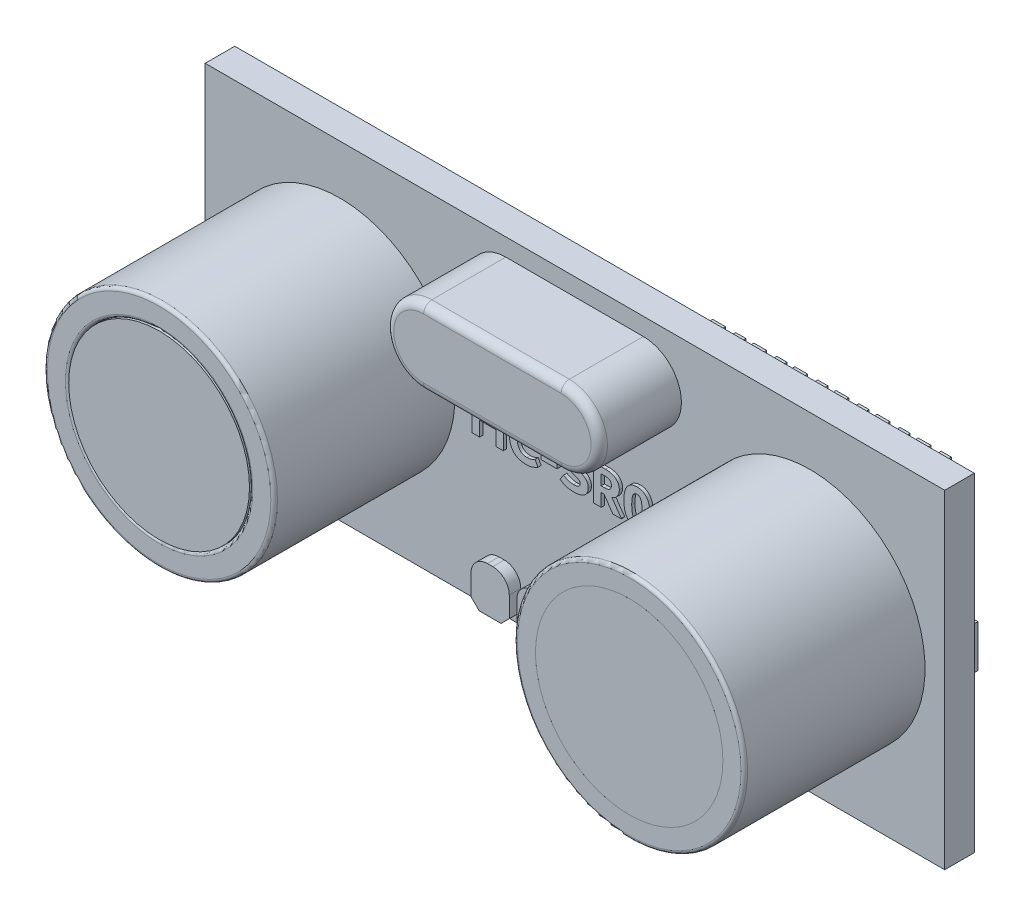
from build123d import *

# Parameters (mm, degrees)
SKETCH2_W            = 45
SKETCH2_H            = 20
BOSS_EXTRUDE1_DEPTH  = 1.8
SKETCH3_R            = 7
SKETCH3_R_2          = 5.5
BOSS_EXTRUDE2_DEPTH  = 11
SKETCH4_R            = 3.606638941
BOSS_EXTRUDE3_DEPTH  = 3
BOSS_EXTRUDE4_DEPTH  = 5
FILLET1_R            = 0.5
FILLET2_R            = 0.2
SKETCH6_R            = 5.5
BOSS_EXTRUDE5_DEPTH  = 0.2
SKETCH8_R            = 5.7
BOSS_EXTRUDE7_DEPTH  = 0.3
BOSS_EXTRUDE8_DEPTH  = 0.7
SKETCH12_W           = 6.997666704
SKETCH12_H           = 2.580972028
SKETCH12_W_2         = 7.281355894
SKETCH12_W_3         = 3.593396415
SKETCH12_H_2         = 7.186792831
BOSS_EXTRUDE9_DEPTH  = 1
SKETCH13_W           = 0.620394056
SKETCH13_H           = 1.706083654
SKETCH13_W_2         = 0.77549257
BOSS_EXTRUDE10_DEPTH = 0.8
SKETCH15_W           = 0.778606998
SKETCH15_H           = 1.881633579
SKETCH15_W_2         = 1.881633579
SKETCH15_H_2         = 0.778606999
SKETCH15_H_3         = 0.778606998
SKETCH15_W_3         = 1.881633578
SKETCH15_W_4         = 0.778606999
SKETCH15_H_4         = 1.881633578
BOSS_EXTRUDE11_DEPTH = 0.8
SKETCH16_W           = 0.977940317
SKETCH16_H           = 0.386305526
BOSS_EXTRUDE12_DEPTH = 0.2


with BuildPart() as part:
    # Sketch2 → Boss-Extrude1 (new body)
    with BuildSketch(Plane.XY):
        Rectangle(SKETCH2_W, SKETCH2_H)
    extrude(amount=BOSS_EXTRUDE1_DEPTH)

    # Sketch3 → Boss-Extrude2 (add)
    with BuildSketch(Plane.XY.offset(1.8)):
        with Locations((-14.302663364, 0)):
            Circle(SKETCH3_R)
        with Locations((-14.302663364, 0)):
            Circle(SKETCH3_R_2, mode=Mode.SUBTRACT)
        with Locations((14.302663364, 0)):
            Circle(SKETCH3_R)
        with Locations((14.302663364, 0)):
            Circle(SKETCH3_R_2, mode=Mode.SUBTRACT)
    extrude(amount=BOSS_EXTRUDE2_DEPTH)

    # Sketch4 → Boss-Extrude3 (add)
    with BuildSketch(Plane.XY.offset(1.8)):
        with Locations((-14.381398614, -0.162523466)):
            Circle(SKETCH4_R)
        with Locations((14.381398614, -0.162523466)):
            Circle(SKETCH4_R)
    extrude(amount=BOSS_EXTRUDE3_DEPTH)

    # Sketch5 → Boss-Extrude4 (add)
    with BuildSketch(Plane.XY.offset(1.8)):
        with BuildLine():
            Line((-4.2079433, 8.933531552), (4.160887825, 8.933531552))
            ThreePointArc((4.160887825, 8.933531552), (6.477682883, 6.616736495), (4.160887825, 4.299941437))
            Line((4.160887825, 4.299941437), (-4.2079433, 4.299941437))
            ThreePointArc((-4.2079433, 4.299941437), (-6.524738357, 6.616736495), (-4.2079433, 8.933531552))
        make_face()
    extrude(amount=BOSS_EXTRUDE4_DEPTH)

    # Fillet1
    fillet1_edges = [part.edges().sort_by_distance(p)[0] for p in [
        (-6.524738357, 6.616736495, 6.8),
        (-0.023527737, 4.299941437, 6.8),
        (6.477682883, 6.616736495, 6.8),
        (-0.023527737, 8.933531552, 6.8),
    ]]
    fillet(fillet1_edges, radius=FILLET1_R)

    # Fillet2
    fillet2_edges = [part.edges().sort_by_distance(p)[0] for p in [
        (-21.302663364, 0, 12.8),
        (-19.802663364, 0, 12.8),
        (7.302663364, 0, 12.8),
        (8.802663364, 0, 12.8),
    ]]
    fillet(fillet2_edges, radius=FILLET2_R)

    # Sketch9 → Boss-Extrude8 (add)
    with BuildSketch(Plane.XY.offset(1.8)):
        with BuildLine():
            Line((-3.296407127, -8.07298027), (-3.296407127, -9.317695877))
            Line((-3.296407127, -9.317695877), (-3.796407127, -9.817695877))
            Line((-3.796407127, -9.817695877), (-5.123806694, -9.817695877))
            Line((-5.123806694, -9.817695877), (-5.623806694, -9.317695877))
            Line((-5.623806694, -9.317695877), (-5.623806694, -8.07298027))
            ThreePointArc((-5.623806694, -8.07298027), (-5.330913475, -7.365873489), (-4.623806694, -7.07298027))
            Line((-4.623806694, -7.07298027), (-4.296407127, -7.07298027))
            ThreePointArc((-4.296407127, -7.07298027), (-3.589300346, -7.365873489), (-3.296407127, -8.07298027))
        make_face()
        with BuildLine():
            ThreePointArc((-2.835845474, -8.07298027), (-2.542952255, -7.365873489), (-1.835845474, -7.07298027))
            Line((-1.835845474, -7.07298027), (-1.268491023, -7.07298027))
            ThreePointArc((-1.268491023, -7.07298027), (-0.561384242, -7.365873489), (-0.268491023, -8.07298027))
            Line((-0.268491023, -8.07298027), (-0.268491023, -9.317695877))
            Line((-0.268491023, -9.317695877), (-0.768491023, -9.817695877))
            Line((-0.768491023, -9.817695877), (-2.335845474, -9.817695877))
            Line((-2.335845474, -9.817695877), (-2.835845474, -9.317695877))
            Line((-2.835845474, -9.317695877), (-2.835845474, -8.07298027))
        make_face()
        with BuildLine():
            ThreePointArc((2.975704802, -8.07298027), (3.268598021, -7.365873489), (3.975704802, -7.07298027))
            Line((3.975704802, -7.07298027), (4.516991532, -7.07298027))
            ThreePointArc((4.516991532, -7.07298027), (5.224098313, -7.365873489), (5.516991532, -8.07298027))
            Line((5.516991532, -8.07298027), (5.516991532, -9.317695877))
            Line((5.516991532, -9.317695877), (5.016991532, -9.817695877))
            Line((5.016991532, -9.817695877), (3.475704802, -9.817695877))
            Line((3.475704802, -9.817695877), (2.975704802, -9.317695877))
            Line((2.975704802, -9.317695877), (2.975704802, -8.07298027))
        make_face()
        with BuildLine():
            ThreePointArc((0.299243246, -8.07298027), (0.592136465, -7.365873489), (1.299243246, -7.07298027))
            Line((1.299243246, -7.07298027), (1.516110394, -7.07298027))
            ThreePointArc((1.516110394, -7.07298027), (2.223217175, -7.365873489), (2.516110394, -8.07298027))
            Line((2.516110394, -8.07298027), (2.516110394, -9.317695877))
            Line((2.516110394, -9.317695877), (2.016110394, -9.817695877))
            Line((2.016110394, -9.817695877), (0.799243246, -9.817695877))
            Line((0.799243246, -9.817695877), (0.299243246, -9.317695877))
            Line((0.299243246, -9.317695877), (0.299243246, -8.07298027))
        make_face()
    extrude(amount=BOSS_EXTRUDE8_DEPTH)

    # Sketch12 → Boss-Extrude9 (add)
    with BuildSketch(Plane(origin=(0, 0, 0), x_dir=(-1, 0, 0), z_dir=(0, 0, -1))):
        with Locations((-18.227030502, 0)):
            Rectangle(SKETCH12_W, SKETCH12_H)
        with Locations((-4.515386285, 0)):
            Rectangle(SKETCH12_W_2, SKETCH12_H)
        with Locations((14.586352554, 0.458930663)):
            Rectangle(SKETCH12_W_3, SKETCH12_H_2)
    extrude(amount=BOSS_EXTRUDE9_DEPTH)

    # Sketch13 → Boss-Extrude10 (add)
    with BuildSketch(Plane(origin=(0, 0, 0), x_dir=(-1, 0, 0), z_dir=(0, 0, -1))):
        with Locations((-17.492981822, 8.497814385)):
            Rectangle(SKETCH13_W, SKETCH13_H)
        with Locations((-19.992981822, 8.497814385)):
            Rectangle(SKETCH13_W, SKETCH13_H)
        with Locations((-18.674644453, 8.497814385)):
            Rectangle(SKETCH13_W_2, SKETCH13_H)
        with Locations((-16.174644453, 8.497814385)):
            Rectangle(SKETCH13_W_2, SKETCH13_H)
        with Locations((-14.992981822, 8.497814385)):
            Rectangle(SKETCH13_W, SKETCH13_H)
        with Locations((-13.674644453, 8.497814385)):
            Rectangle(SKETCH13_W_2, SKETCH13_H)
        with Locations((-12.492981822, 8.497814385)):
            Rectangle(SKETCH13_W, SKETCH13_H)
        with Locations((-11.174644453, 8.497814385)):
            Rectangle(SKETCH13_W_2, SKETCH13_H)
        with Locations((-9.992981822, 8.497814385)):
            Rectangle(SKETCH13_W, SKETCH13_H)
        with Locations((-8.674644453, 8.497814385)):
            Rectangle(SKETCH13_W_2, SKETCH13_H)
        with Locations((-7.492981822, 8.497814385)):
            Rectangle(SKETCH13_W, SKETCH13_H)
        with Locations((-6.174644453, 8.497814385)):
            Rectangle(SKETCH13_W_2, SKETCH13_H)
        with Locations((-17.492981822, -5.502185615)):
            Rectangle(SKETCH13_W, SKETCH13_H)
        with Locations((-16.174644453, -5.502185615)):
            Rectangle(SKETCH13_W_2, SKETCH13_H)
        with Locations((-14.992981822, -5.502185615)):
            Rectangle(SKETCH13_W, SKETCH13_H)
        with Locations((-13.674644453, -5.502185615)):
            Rectangle(SKETCH13_W_2, SKETCH13_H)
        with Locations((-12.492981822, -5.502185615)):
            Rectangle(SKETCH13_W, SKETCH13_H)
        with Locations((-11.174644453, -5.502185615)):
            Rectangle(SKETCH13_W_2, SKETCH13_H)
        with Locations((-9.992981822, -5.502185615)):
            Rectangle(SKETCH13_W, SKETCH13_H)
        with Locations((-8.674644453, -5.502185615)):
            Rectangle(SKETCH13_W_2, SKETCH13_H)
        with Locations((-7.492981822, -5.502185615)):
            Rectangle(SKETCH13_W, SKETCH13_H)
        with Locations((-6.174644453, -5.502185615)):
            Rectangle(SKETCH13_W_2, SKETCH13_H)
        with Locations((-19.992981822, -5.502185615)):
            Rectangle(SKETCH13_W, SKETCH13_H)
        with Locations((-18.674644453, -5.502185615)):
            Rectangle(SKETCH13_W_2, SKETCH13_H)
    extrude(amount=BOSS_EXTRUDE10_DEPTH)

    # Sketch15 → Boss-Extrude11 (add)
    with BuildSketch(Plane(origin=(0, 0, 0), x_dir=(-1, 0, 0), z_dir=(0, 0, -1))):
        with Locations((4.436153711, 3.859373901)):
            Rectangle(SKETCH15_W, SKETCH15_H)
        with Locations((4.436153711, -0.149576125)):
            Rectangle(SKETCH15_W, SKETCH15_H)
        with Locations((2.818394099, 1.651139133)):
            Rectangle(SKETCH15_W, SKETCH15_H)
        with Locations((15.278254299, -7.403939958)):
            Rectangle(SKETCH15_W_2, SKETCH15_H_2)
        with Locations((13.07001953, -5.786180346)):
            Rectangle(SKETCH15_W_2, SKETCH15_H_3)
        with Locations((17.078969556, -5.786180346)):
            Rectangle(SKETCH15_W_2, SKETCH15_H_3)
        with Locations((-11.40707472, 2.879595245)):
            Rectangle(SKETCH15_W_2, SKETCH15_H_3)
        with Locations((1.45501374, 8.522939867)):
            Rectangle(SKETCH15_W_3, SKETCH15_H_3)
        with Locations((13.861551289, 8.522939867)):
            Rectangle(SKETCH15_W_2, SKETCH15_H_3)
        with Locations((17.870501316, 8.522939867)):
            Rectangle(SKETCH15_W_2, SKETCH15_H_3)
        with Locations((7.763207417, 3.859373901)):
            Rectangle(SKETCH15_W, SKETCH15_H)
        with Locations((6.145447805, 1.651139133)):
            Rectangle(SKETCH15_W_4, SKETCH15_H)
        with Locations((7.763207417, -0.149576125)):
            Rectangle(SKETCH15_W, SKETCH15_H)
        with Locations((-15.265133185, 3.268898744)):
            Rectangle(SKETCH15_W, SKETCH15_H_4)
        with Locations((10.154397832, -2.650143964)):
            Rectangle(SKETCH15_W_2, SKETCH15_H_3)
        with Locations((6.145447805, -2.650143964)):
            Rectangle(SKETCH15_W_2, SKETCH15_H_3)
    extrude(amount=BOSS_EXTRUDE11_DEPTH)

    # Sketch16 → Boss-Extrude12 (add)
    with BuildSketch(Plane.XY.offset(1.8)):
        Polygon((-4.614623459, 0.989969493), (-4.159078995, 0.989969493), (-4.159078995, -1.149274951), (-4.614623459, -1.149274951), (-4.614623459, -0.261584009), (-5.598293896, -0.261584009), (-5.598293896, -1.149274951), (-6.05383836, -1.149274951), (-6.05383836, 0.989969493), (-5.598293896, 0.989969493), (-5.598293896, 0.134271715), (-4.614623459, 0.134271715), align=None)
        with BuildLine():
            add(Edge.make_bspline(
                [(-2.758542398, -1.179835586), (-2.80187664, -1.178955464), (-2.885596469, -1.177255107), (-3.006695539, -1.163195093), (-3.118814713, -1.140601797), (-3.222290792, -1.108873564), (-3.31660546, -1.067012359), (-3.402238463, -1.016483129), (-3.47869818, -0.95607153), (-3.545546014, -0.886382582), (-3.603845021, -0.809125233), (-3.65404661, -0.725337162), (-3.697369581, -0.635842986), (-3.732010739, -0.539725429), (-3.759438653, -0.437689309), (-3.777979965, -0.329125864), (-3.790453858, -0.214601041), (-3.791709684, -0.136033786), (-3.792351376, -0.095888067)],
                knots=[0, 0, 0, 0, 0.00012997, 0.000251097, 0.000365161, 0.000472695, 0.000575093, 0.000674019, 0.000770222, 0.000866467, 0.000962925, 0.001059968, 0.001159066, 0.001260731, 0.001366019, 0.001475614, 0.001590836, 0.001711229, 0.001711229, 0.001711229, 0.001711229], degree=3))
            add(Edge.make_bspline(
                [(-3.792351376, -0.095888067), (-3.791822721, -0.063250776), (-3.790792806, 0.0003326), (-3.784820228, 0.093462721), (-3.773598156, 0.18169843), (-3.759229146, 0.265545694), (-3.739584757, 0.34449491), (-3.715606153, 0.418592185), (-3.688250618, 0.48835354), (-3.655333083, 0.552772361), (-3.619624533, 0.613197884), (-3.580488153, 0.668934089), (-3.538608713, 0.720401393), (-3.494420927, 0.767845351), (-3.446801433, 0.810444616), (-3.396694243, 0.848905976), (-3.343221649, 0.882324744), (-3.287326919, 0.911911458), (-3.229067928, 0.937735057), (-3.168712051, 0.959355259), (-3.107076402, 0.978883648), (-3.04334277, 0.993950716), (-2.977835979, 1.005895105), (-2.91058762, 1.014577249), (-2.841535022, 1.019203589), (-2.794998458, 1.020084227), (-2.771435166, 1.020530128)],
                knots=[0, 0, 0, 0, 9.7919e-05, 0.000190763, 0.000279783, 0.000364648, 0.000445833, 0.000523603, 0.000598175, 0.000670355, 0.000740374, 0.000808597, 0.000874449, 0.000939309, 0.001002877, 0.00106591, 0.001128573, 0.001191802, 0.001255509, 0.00131956, 0.001384052, 0.001449373, 0.001515872, 0.001583748, 0.001652675, 0.001723372, 0.001723372, 0.001723372, 0.001723372], degree=3))
            add(Edge.make_bspline(
                [(-2.771435166, 1.020530128), (-2.738625698, 1.020028472), (-2.674149486, 1.019042632), (-2.579661415, 1.009866748), (-2.489383691, 0.994511909), (-2.402532635, 0.973406459), (-2.317760913, 0.945748739), (-2.23361758, 0.912135134), (-2.149183122, 0.872674609), (-2.09444195, 0.841529469), (-2.066630523, 0.82570608)],
                knots=[0, 0, 0, 0, 9.8409e-05, 0.00019339, 0.000284453, 0.000372936, 0.000461275, 0.00055172, 0.000644638, 0.000740599, 0.000740599, 0.000740599, 0.000740599], degree=3))
            Line((-2.066630523, 0.82570608), (-2.241876664, 0.479033878))
            add(Edge.make_bspline(
                [(-2.241876664, 0.479033878), (-2.26141849, 0.491314035), (-2.300137703, 0.515645334), (-2.36132151, 0.545922953), (-2.423259473, 0.572319222), (-2.486385802, 0.594017993), (-2.550989694, 0.610166675), (-2.616687134, 0.622118995), (-2.683722883, 0.629517226), (-2.728759178, 0.63042572), (-2.751379749, 0.630882033)],
                knots=[0, 0, 0, 0, 6.9199e-05, 0.000137108, 0.000204512, 0.000271105, 0.000337119, 0.000404088, 0.000471322, 0.00053917, 0.00053917, 0.00053917, 0.00053917], degree=3))
            add(Edge.make_bspline(
                [(-2.751379749, 0.630882033), (-2.774006962, 0.63032934), (-2.817822736, 0.629259096), (-2.881499941, 0.621073632), (-2.940734732, 0.607393487), (-2.995771228, 0.588068365), (-3.04670018, 0.563927439), (-3.093031572, 0.533621004), (-3.134332958, 0.497197271), (-3.171775313, 0.455969504), (-3.205090156, 0.409321461), (-3.233054979, 0.356581975), (-3.257549899, 0.298845149), (-3.276870108, 0.235391485), (-3.292116456, 0.166744094), (-3.303035667, 0.092708503), (-3.309020461, 0.013083107), (-3.310024831, -0.041760578), (-3.310543866, -0.070102531)],
                knots=[0, 0, 0, 0, 6.7867e-05, 0.000131419, 0.000192228, 0.000249918, 0.000306087, 0.000360918, 0.000415406, 0.000470847, 0.000527689, 0.000586873, 0.000649574, 0.000715576, 0.000785549, 0.000860373, 0.000939883, 0.001024913, 0.001024913, 0.001024913, 0.001024913], degree=3))
            add(Edge.make_bspline(
                [(-3.310543866, -0.070102531), (-3.310096669, -0.098288574), (-3.309228525, -0.153006104), (-3.302219357, -0.232527703), (-3.289602227, -0.306644129), (-3.273355303, -0.375856327), (-3.251115094, -0.439698537), (-3.224671067, -0.498606417), (-3.192900663, -0.552076354), (-3.15645818, -0.600218777), (-3.115311022, -0.642748852), (-3.070140708, -0.679775274), (-3.020920542, -0.711375841), (-2.967205546, -0.736207207), (-2.909997614, -0.756880084), (-2.848471704, -0.770125918), (-2.783164161, -0.779177353), (-2.738202136, -0.780141608), (-2.715088995, -0.780637293)],
                knots=[0, 0, 0, 0, 8.4553e-05, 0.000164143, 0.000239191, 0.000309954, 0.000377154, 0.000441689, 0.000503354, 0.00056333, 0.000622428, 0.000680451, 0.000738206, 0.000797373, 0.000857632, 0.000920302, 0.00098581, 0.001055108, 0.001055108, 0.001055108, 0.001055108], degree=3))
            add(Edge.make_bspline(
                [(-2.715088995, -0.780637293), (-2.691508775, -0.780228522), (-2.6458247, -0.779436572), (-2.579780962, -0.771947939), (-2.518087602, -0.761011915), (-2.460318864, -0.743606798), (-2.40428795, -0.722041592), (-2.347646342, -0.697154753), (-2.29012624, -0.667980662), (-2.251826094, -0.646440798), (-2.232326465, -0.635474277)],
                knots=[0, 0, 0, 0, 7.0712e-05, 0.000136996, 0.000199183, 0.000258413, 0.000317655, 0.00037923, 0.000443936, 0.000511047, 0.000511047, 0.000511047, 0.000511047], degree=3))
            Line((-2.232326465, -0.635474277), (-2.050395186, -0.965433632))
            add(Edge.make_bspline(
                [(-2.050395186, -0.965433632), (-2.079650931, -0.982339665), (-2.137018978, -1.01549097), (-2.224741401, -1.05832536), (-2.311240452, -1.095284975), (-2.397189523, -1.126246919), (-2.484039229, -1.150756995), (-2.573279231, -1.166961728), (-2.664986321, -1.178134706), (-2.72715172, -1.179264893), (-2.758542398, -1.179835586)],
                knots=[0, 0, 0, 0, 0.000101341, 0.000198722, 0.000292647, 0.00038342, 0.000472626, 0.000563002, 0.000655284, 0.000749413, 0.000749413, 0.000749413, 0.000749413], degree=3))
        make_face()
        with Locations((-1.378061217, -0.272805492)):
            Rectangle(SKETCH16_W, SKETCH16_H)
        with BuildLine():
            add(Edge.make_bspline(
                [(0.14328539, -1.179835586), (0.102342007, -1.179228217), (0.022008476, -1.178036519), (-0.096025855, -1.164915061), (-0.209437589, -1.145291044), (-0.318342238, -1.116968135), (-0.422472784, -1.080730944), (-0.522091339, -1.036566673), (-0.616933853, -0.984207532), (-0.676137535, -0.943035381), (-0.705727249, -0.922457739)],
                knots=[0, 0, 0, 0, 0.000122779, 0.000240901, 0.000355834, 0.000467831, 0.000578072, 0.00068624, 0.000794397, 0.000902467, 0.000902467, 0.000902467, 0.000902467], degree=3))
            Line((-0.705727249, -0.922457739), (-0.491802805, -0.595363444))
            add(Edge.make_bspline(
                [(-0.491802805, -0.595363444), (-0.466244068, -0.611052361), (-0.416041042, -0.641868873), (-0.338211964, -0.680301833), (-0.261934865, -0.715144543), (-0.185330792, -0.741822263), (-0.109651457, -0.764137782), (-0.033925633, -0.778262583), (0.041122362, -0.788808698), (0.091200008, -0.789729997), (0.116067324, -0.790187491)],
                knots=[0, 0, 0, 0, 8.9919e-05, 0.000176621, 0.000260207, 0.000341312, 0.000419759, 0.000496644, 0.000572219, 0.000646766, 0.000646766, 0.000646766, 0.000646766], degree=3))
            add(Edge.make_bspline(
                [(0.116067324, -0.790187491), (0.146179994, -0.789447666), (0.203106031, -0.788049075), (0.283596818, -0.777927184), (0.353860702, -0.760120761), (0.405195954, -0.738740266), (0.440368555, -0.717836557), (0.462687901, -0.700336873), (0.481527993, -0.680990714), (0.497337413, -0.660163467), (0.509064927, -0.637122117), (0.518006084, -0.612479667), (0.522569677, -0.585819104), (0.523422433, -0.567522919), (0.523860797, -0.55811767)],
                knots=[0, 0, 0, 0, 9.033e-05, 0.000170763, 0.000242802, 0.000307196, 0.000336759, 0.000365322, 0.000391998, 0.000417593, 0.000443436, 0.000469261, 0.000495955, 0.000524193, 0.000524193, 0.000524193, 0.000524193], degree=3))
            add(Edge.make_bspline(
                [(0.523860797, -0.55811767), (0.523325401, -0.546800315), (0.522291383, -0.524942919), (0.516539904, -0.493370296), (0.504527862, -0.465407343), (0.488880958, -0.439446604), (0.467095496, -0.415612133), (0.438610047, -0.393149644), (0.40378554, -0.37098854), (0.361477421, -0.34868974), (0.310449069, -0.325252333), (0.249162163, -0.29894633), (0.176548176, -0.270099384), (0.124361522, -0.249919053), (0.096489418, -0.239141043)],
                knots=[0, 0, 0, 0, 3.3987e-05, 6.564e-05, 9.5613e-05, 0.000124769, 0.000156215, 0.000191863, 0.000233321, 0.000279892, 0.000335222, 0.000401746, 0.000479955, 0.000569606, 0.000569606, 0.000569606, 0.000569606], degree=3))
            Line((0.096489418, -0.239141043), (0.018655301, -0.210012938))
            add(Edge.make_bspline(
                [(0.018655301, -0.210012938), (-0.015457171, -0.196613756), (-0.080635423, -0.171012114), (-0.172927625, -0.132415166), (-0.25422971, -0.09333346), (-0.326709212, -0.056046934), (-0.390322027, -0.015196636), (-0.446575731, 0.030088569), (-0.495602107, 0.081278398), (-0.538365649, 0.137453701), (-0.573064801, 0.200681799), (-0.596490397, 0.272230702), (-0.611740998, 0.350892583), (-0.613259139, 0.406057178), (-0.614045344, 0.434625455)],
                knots=[0, 0, 0, 0, 0.000109953, 0.000210085, 0.000300006, 0.000380537, 0.000454444, 0.000526411, 0.000596655, 0.000666562, 0.000737713, 0.000811856, 0.000891555, 0.000977162, 0.000977162, 0.000977162, 0.000977162], degree=3))
            add(Edge.make_bspline(
                [(-0.614045344, 0.434625455), (-0.613638398, 0.450871417), (-0.612842272, 0.48265405), (-0.607772677, 0.529396106), (-0.59796347, 0.573880108), (-0.585159834, 0.616393746), (-0.56899671, 0.657081335), (-0.548112025, 0.695159034), (-0.524422289, 0.731757947), (-0.486967293, 0.776903101), (-0.433801307, 0.828284468), (-0.36129517, 0.881358003), (-0.280428042, 0.925367802), (-0.191885783, 0.960343655), (-0.097978129, 0.986904389), (-0.000491335, 1.006778974), (0.100028017, 1.018347994), (0.168086707, 1.019797347), (0.20249662, 1.020530128)],
                knots=[0, 0, 0, 0, 4.8743e-05, 9.5359e-05, 0.000140783, 0.000185193, 0.000228465, 0.000271835, 0.000315275, 0.000359053, 0.000447527, 0.000536349, 0.000627812, 0.000722957, 0.000821343, 0.000920235, 0.001021165, 0.001124378, 0.001124378, 0.001124378, 0.001124378], degree=3))
            add(Edge.make_bspline(
                [(0.20249662, 1.020530128), (0.234364619, 1.019787339), (0.298619778, 1.018289661), (0.395654969, 1.006177559), (0.493954626, 0.987142641), (0.593226057, 0.960363412), (0.691926535, 0.926064874), (0.789278897, 0.885017641), (0.884124273, 0.836333892), (0.944646437, 0.798453226), (0.975107672, 0.779387618)],
                knots=[0, 0, 0, 0, 9.5578e-05, 0.000192714, 0.000292918, 0.000395777, 0.000500881, 0.000606156, 0.000712511, 0.000820282, 0.000820282, 0.000820282, 0.000820282], degree=3))
            Line((0.975107672, 0.779387618), (0.754975598, 0.456113402))
            add(Edge.make_bspline(
                [(0.754975598, 0.456113402), (0.728822906, 0.471112059), (0.678462702, 0.499993807), (0.604269898, 0.538397819), (0.534268194, 0.569348356), (0.468302192, 0.595322079), (0.402856139, 0.614030109), (0.336421832, 0.628333779), (0.267125857, 0.635686942), (0.220178913, 0.636933059), (0.196288991, 0.637567172)],
                knots=[0, 0, 0, 0, 9.0442e-05, 0.000174158, 0.000250471, 0.000319998, 0.000386639, 0.000454442, 0.000523627, 0.000595311, 0.000595311, 0.000595311, 0.000595311], degree=3))
            add(Edge.make_bspline(
                [(0.196288991, 0.637567172), (0.170789822, 0.636969011), (0.122931503, 0.635846349), (0.055845141, 0.626562835), (-0.001448858, 0.610831736), (-0.048963023, 0.588462807), (-0.085855622, 0.560127259), (-0.113313134, 0.527201046), (-0.129217762, 0.488613988), (-0.131221801, 0.461343941), (-0.132237834, 0.447518223)],
                knots=[0, 0, 0, 0, 7.6475e-05, 0.000143532, 0.00020263, 0.000254099, 0.000300042, 0.000341133, 0.000381391, 0.000422791, 0.000422791, 0.000422791, 0.000422791], degree=3))
            add(Edge.make_bspline(
                [(-0.132237834, 0.447518223), (-0.132007481, 0.438541837), (-0.131556176, 0.420955365), (-0.123853416, 0.395637479), (-0.114456061, 0.370978352), (-0.098875089, 0.34798774), (-0.077942232, 0.325990151), (-0.051082669, 0.304043757), (-0.017047521, 0.282877984), (0.023555967, 0.260430638), (0.072937914, 0.238430195), (0.130948835, 0.213833164), (0.198594911, 0.187898064), (0.247034903, 0.170321495), (0.272690578, 0.161012271)],
                knots=[0, 0, 0, 0, 2.6809e-05, 5.2523e-05, 7.886e-05, 0.000105745, 0.000135138, 0.000169744, 0.000209481, 0.000255212, 0.00030884, 0.000371541, 0.000444256, 0.000526135, 0.000526135, 0.000526135, 0.000526135], degree=3))
            Line((0.272690578, 0.161012271), (0.346227106, 0.134749225))
            add(Edge.make_bspline(
                [(0.346227106, 0.134749225), (0.380372314, 0.122231028), (0.445490477, 0.098357636), (0.537224441, 0.060895629), (0.618961346, 0.025357904), (0.691754685, -0.009656955), (0.757360864, -0.047641906), (0.815844773, -0.093550482), (0.869042675, -0.1465273), (0.909145113, -0.195868113), (0.936996584, -0.239611649), (0.955892061, -0.274850842), (0.97074499, -0.312874125), (0.984197093, -0.352692421), (0.993180832, -0.395226061), (1.000615269, -0.439958256), (1.004855592, -0.487046394), (1.005394178, -0.519272373), (1.005668307, -0.535674703)],
                knots=[0, 0, 0, 0, 0.000109094, 0.000208053, 0.000297215, 0.000376445, 0.000450312, 0.000524147, 0.000598769, 0.000675208, 0.000714285, 0.000754228, 0.000794928, 0.000836606, 0.000880164, 0.000925146, 0.000972615, 0.001021819, 0.001021819, 0.001021819, 0.001021819], degree=3))
            add(Edge.make_bspline(
                [(1.005668307, -0.535674703), (1.005287571, -0.553038868), (1.004541785, -0.587051884), (0.999094129, -0.636991836), (0.990744239, -0.684805134), (0.978286226, -0.730538868), (0.961757542, -0.773916368), (0.942961116, -0.815769584), (0.919742632, -0.855183037), (0.884005073, -0.904613418), (0.832165312, -0.961718749), (0.759372698, -1.020880003), (0.67609073, -1.07017593), (0.583646594, -1.110551646), (0.483026857, -1.141871073), (0.375260291, -1.163225196), (0.261469748, -1.177829223), (0.183285419, -1.179156524), (0.14328539, -1.179835586)],
                knots=[0, 0, 0, 0, 5.2084e-05, 0.000102022, 0.00015054, 0.000197572, 0.000243959, 0.000289683, 0.000335054, 0.000380905, 0.000472513, 0.000565511, 0.000661244, 0.000761945, 0.000867514, 0.000976708, 0.001091196, 0.001211128, 0.001211128, 0.001211128, 0.001211128], degree=3))
        make_face()
        with BuildLine():
            Line((3.022670211, -1.123011906), (3.022670211, -1.149274951))
            Line((3.022670211, -1.149274951), (2.505526967, -1.149274951))
            Line((2.505526967, -1.149274951), (1.975013445, -0.371888801))
            Line((1.975013445, -0.371888801), (1.797379755, -0.371888801))
            Line((1.797379755, -0.371888801), (1.797379755, -1.149274951))
            Line((1.797379755, -1.149274951), (1.341835291, -1.149274951))
            Line((1.341835291, -1.149274951), (1.341835291, 0.989969493))
            Line((1.341835291, 0.989969493), (2.055235112, 0.989969493))
            add(Edge.make_bspline(
                [(2.055235112, 0.989969493), (2.078317242, 0.989642161), (2.123558255, 0.98900059), (2.189900667, 0.985519529), (2.253244184, 0.977961827), (2.313746731, 0.968854789), (2.371329539, 0.956052892), (2.42628276, 0.941810628), (2.477917223, 0.92328808), (2.526770511, 0.90286718), (2.572521268, 0.879987342), (2.615226578, 0.855041303), (2.654994265, 0.828301552), (2.691814501, 0.799551807), (2.726054527, 0.769134529), (2.7563323, 0.735904806), (2.78455756, 0.701568721), (2.816623777, 0.652417769), (2.850316787, 0.587129652), (2.87965889, 0.503487317), (2.897333888, 0.41435489), (2.89938063, 0.353211773), (2.900427672, 0.321933114)],
                knots=[0, 0, 0, 0, 6.9254e-05, 0.000135737, 0.000199174, 0.000260566, 0.000319196, 0.00037607, 0.00043074, 0.000483597, 0.000534849, 0.00058407, 0.00063188, 0.000678493, 0.000724137, 0.000769077, 0.000813225, 0.000857327, 0.000944888, 0.001032933, 0.001122461, 0.001216228, 0.001216228, 0.001216228, 0.001216228], degree=3))
            add(Edge.make_bspline(
                [(2.900427672, 0.321933114), (2.900033045, 0.303457892), (2.899259176, 0.267227749), (2.89397462, 0.213739436), (2.884885361, 0.162381234), (2.872509405, 0.112665839), (2.856127773, 0.065024436), (2.836814991, 0.018961661), (2.812899161, -0.024633607), (2.786482471, -0.066836917), (2.755794522, -0.106206622), (2.722190433, -0.143503543), (2.684763881, -0.177584042), (2.644605651, -0.210008186), (2.600522021, -0.239043531), (2.553062626, -0.265073202), (2.502767185, -0.289481187), (2.467290188, -0.302625452), (2.449180797, -0.309335001)],
                knots=[0, 0, 0, 0, 5.5424e-05, 0.000108687, 0.00016105, 0.000211777, 0.000262212, 0.000312059, 0.000361411, 0.000411219, 0.000461267, 0.000510957, 0.000561645, 0.000612953, 0.000665663, 0.000719742, 0.000775275, 0.00083318, 0.00083318, 0.00083318, 0.00083318], degree=3))
            Line((2.449180797, -0.309335001), (3.022670211, -1.123011906))
        make_face()
        with BuildLine():
            Line((1.797379755, -0.018531459), (2.001276491, -0.018531459))
            add(Edge.make_bspline(
                [(2.001276491, -0.018531459), (2.017523057, -0.018455847), (2.049110562, -0.018308836), (2.094814523, -0.014096371), (2.137819035, -0.008784807), (2.177771943, 4.582e-05), (2.215185955, 0.010395362), (2.249805515, 0.022983579), (2.280911258, 0.039266926), (2.309918295, 0.056509939), (2.335574017, 0.077457801), (2.358106755, 0.10122449), (2.376986282, 0.12848261), (2.392218899, 0.158752232), (2.40412623, 0.191957683), (2.412865266, 0.228108227), (2.417349568, 0.267544259), (2.418186103, 0.294864497), (2.418620162, 0.309040346)],
                knots=[0, 0, 0, 0, 4.8715e-05, 9.4715e-05, 0.000137598, 0.00017862, 0.000217319, 0.000254037, 0.000288846, 0.000322506, 0.000355096, 0.000387864, 0.00042045, 0.000454192, 0.000489236, 0.000526066, 0.000565512, 0.000608053, 0.000608053, 0.000608053, 0.000608053], degree=3))
            add(Edge.make_bspline(
                [(2.418620162, 0.309040346), (2.418398517, 0.321313618), (2.417964939, 0.345322351), (2.413053651, 0.380014978), (2.405473635, 0.412347143), (2.394953107, 0.442157281), (2.381464332, 0.469806787), (2.3648266, 0.49504563), (2.344956371, 0.517915988), (2.313834718, 0.544685048), (2.26827679, 0.573525029), (2.204162534, 0.596898471), (2.130850948, 0.611408548), (2.078867723, 0.612902637), (2.051415033, 0.613691675)],
                knots=[0, 0, 0, 0, 3.6796e-05, 7.198e-05, 0.000104873, 0.000136287, 0.000166612, 0.00019694, 0.000226722, 0.000257178, 0.000319841, 0.000387243, 0.000460756, 0.000543027, 0.000543027, 0.000543027, 0.000543027], degree=3))
            Line((2.051415033, 0.613691675), (1.797379755, 0.613691675))
            Line((1.797379755, 0.613691675), (1.797379755, -0.018531459))
        make_face(mode=Mode.SUBTRACT)
        with BuildLine():
            add(Edge.make_bspline(
                [(3.950471987, -1.179835586), (3.930877174, -1.179499291), (3.892397115, -1.178838877), (3.83564808, -1.172708568), (3.780851637, -1.163961429), (3.72813632, -1.151058738), (3.6775927, -1.134109377), (3.62891443, -1.113799832), (3.582503526, -1.089120503), (3.537895836, -1.061547053), (3.495593837, -1.029876942), (3.45599485, -0.993885368), (3.418650261, -0.954111936), (3.383624164, -0.910415641), (3.351162628, -0.862703238), (3.321730485, -0.810700191), (3.293855922, -0.755434547), (3.268970961, -0.695919935), (3.24729816, -0.632305858), (3.22751476, -0.565027349), (3.211283702, -0.493580756), (3.198826553, -0.41824595), (3.188109569, -0.339133247), (3.180515588, -0.256139343), (3.176284112, -0.169151568), (3.175747377, -0.109899597), (3.175473386, -0.079652729)],
                knots=[0, 0, 0, 0, 5.8765e-05, 0.000115402, 0.00017106, 0.000225145, 0.000277996, 0.000330853, 0.000383183, 0.00043552, 0.000488046, 0.000541463, 0.000595851, 0.000651558, 0.000709303, 0.000768768, 0.000830698, 0.000894904, 0.000962104, 0.001032222, 0.0011052, 0.00118174, 0.001261227, 0.001344664, 0.001431677, 0.001522415, 0.001522415, 0.001522415, 0.001522415], degree=3))
            add(Edge.make_bspline(
                [(3.175473386, -0.079652729), (3.175823982, -0.045264434), (3.176506211, 0.021652261), (3.182243857, 0.119170785), (3.191874968, 0.210905969), (3.204320198, 0.297268212), (3.221770034, 0.3778251), (3.241795275, 0.453210232), (3.266984134, 0.522581451), (3.294875515, 0.58691078), (3.326839382, 0.645397528), (3.359659304, 0.69992159), (3.394867934, 0.749331163), (3.431905752, 0.794313543), (3.470988239, 0.834477501), (3.512151846, 0.869803426), (3.554858669, 0.900956762), (3.614811985, 0.934676756), (3.69238871, 0.96926944), (3.788902444, 0.998942005), (3.888322211, 1.017445192), (3.955644687, 1.019495282), (3.989627801, 1.020530128)],
                knots=[0, 0, 0, 0, 0.00010316, 0.00020074, 0.000292918, 0.000379832, 0.000462341, 0.000540071, 0.000613628, 0.000683542, 0.000750197, 0.00081342, 0.000874369, 0.000932024, 0.000988078, 0.001042253, 0.001094599, 0.001146364, 0.001248326, 0.001348768, 0.001448709, 0.00155058, 0.00155058, 0.00155058, 0.00155058], degree=3))
            add(Edge.make_bspline(
                [(3.989627801, 1.020530128), (4.019281233, 1.019717138), (4.077265202, 1.018127427), (4.161748793, 1.005335891), (4.241412972, 0.985275463), (4.315657223, 0.955637564), (4.3850882, 0.918260124), (4.44932904, 0.872089968), (4.508384781, 0.817663127), (4.562374086, 0.755081061), (4.610356657, 0.683294032), (4.651921293, 0.601831609), (4.68714229, 0.510768912), (4.715415504, 0.409954863), (4.73789619, 0.299697769), (4.75309885, 0.179663011), (4.762801674, 0.049912148), (4.7640037, -0.039841534), (4.764626402, -0.086337868)],
                knots=[0, 0, 0, 0, 8.8921e-05, 0.000173875, 0.000255757, 0.000334853, 0.000413054, 0.000491766, 0.000571523, 0.00065346, 0.000739148, 0.000829912, 0.000927277, 0.001031567, 0.001143664, 0.001264551, 0.001394308, 0.001533781, 0.001533781, 0.001533781, 0.001533781], degree=3))
            add(Edge.make_bspline(
                [(4.764626402, -0.086337868), (4.763903381, -0.135382608), (4.762511722, -0.229783183), (4.751674716, -0.365707163), (4.733314816, -0.490034457), (4.707899788, -0.602952521), (4.674739891, -0.704401154), (4.633641108, -0.794319209), (4.585651689, -0.873149156), (4.529303671, -0.939599877), (4.468070083, -0.995977983), (4.403765911, -1.045030906), (4.336245186, -1.086905062), (4.265279082, -1.120854886), (4.191220683, -1.147433469), (4.113850911, -1.165797301), (4.033294526, -1.177770839), (3.978370249, -1.179140089), (3.950471987, -1.179835586)],
                knots=[0, 0, 0, 0, 0.000147123, 0.000283179, 0.000408721, 0.00052386, 0.000630015, 0.000728299, 0.000819864, 0.000905949, 0.000988729, 0.001069144, 0.001148258, 0.001226641, 0.001304726, 0.001383829, 0.001464865, 0.001548516, 0.001548516, 0.001548516, 0.001548516], degree=3))
        make_face()
        with BuildLine():
            add(Edge.make_bspline(
                [(3.960499695, -0.783979862), (3.978420124, -0.783244466), (4.013014667, -0.781824819), (4.06219963, -0.768317726), (4.106620067, -0.74731268), (4.145836391, -0.716546956), (4.180454417, -0.676367586), (4.209252626, -0.625245069), (4.233376782, -0.563969392), (4.248984277, -0.5058948), (4.259375003, -0.453999072), (4.266498936, -0.410512551), (4.272673864, -0.363532748), (4.277927694, -0.313229604), (4.281778188, -0.259561093), (4.283795664, -0.202538978), (4.28608133, -0.142223575), (4.286134347, -0.100824905), (4.286161461, -0.079652729)],
                knots=[0, 0, 0, 0, 5.3654e-05, 0.000103576, 0.000151842, 0.000200172, 0.000251966, 0.000309951, 0.000375302, 0.000449096, 0.00049002, 0.000534059, 0.000581265, 0.000632153, 0.000685771, 0.000742644, 0.000803318, 0.000866829, 0.000866829, 0.000866829, 0.000866829], degree=3))
            add(Edge.make_bspline(
                [(4.286161461, -0.079652729), (4.286026201, -0.050998713), (4.285764596, 0.004420605), (4.28240096, 0.084848187), (4.276746113, 0.159539118), (4.26903852, 0.228647619), (4.259985378, 0.29220942), (4.247401106, 0.350001107), (4.233213564, 0.402179544), (4.217181433, 0.449024967), (4.198202621, 0.490277471), (4.176195921, 0.526302078), (4.150662681, 0.556430823), (4.122825136, 0.5819992), (4.091221836, 0.601438935), (4.056490946, 0.614590062), (4.019002553, 0.623109949), (3.993018922, 0.624141616), (3.979600092, 0.624674404)],
                knots=[0, 0, 0, 0, 8.5957e-05, 0.000166248, 0.000241436, 0.000310621, 0.000374844, 0.000433941, 0.000487925, 0.000537006, 0.000582297, 0.000623903, 0.000663216, 0.000700413, 0.000736857, 0.000773746, 0.0008114, 0.000851613, 0.000851613, 0.000851613, 0.000851613], degree=3))
            add(Edge.make_bspline(
                [(3.979600092, 0.624674404), (3.961691844, 0.623914388), (3.927120814, 0.622447213), (3.877633111, 0.609237234), (3.833412462, 0.586770888), (3.793744732, 0.555611958), (3.759730456, 0.513918912), (3.730800424, 0.462128181), (3.706686685, 0.399508488), (3.686857057, 0.32605971), (3.672000447, 0.240696405), (3.661185415, 0.143109242), (3.655410162, 0.032631162), (3.654446452, -0.045265872), (3.653938326, -0.086337868)],
                knots=[0, 0, 0, 0, 5.3654e-05, 0.000103576, 0.000152265, 0.00020156, 0.000253772, 0.000312586, 0.000378824, 0.000454585, 0.000540475, 0.000638504, 0.000748983, 0.000872204, 0.000872204, 0.000872204, 0.000872204], degree=3))
            add(Edge.make_bspline(
                [(3.653938326, -0.086337868), (3.654075194, -0.114991767), (3.654339907, -0.170410857), (3.657675273, -0.250681421), (3.663384201, -0.325209114), (3.671033075, -0.394004632), (3.680051833, -0.457102155), (3.692756965, -0.514233428), (3.706900395, -0.565777889), (3.722784638, -0.612066127), (3.742045947, -0.652547736), (3.763768461, -0.687964285), (3.789434264, -0.717259733), (3.817577806, -0.74175234), (3.848853062, -0.761220941), (3.883552303, -0.774510595), (3.921163781, -0.782253808), (3.947092168, -0.783391542), (3.960499695, -0.783979862)],
                knots=[0, 0, 0, 0, 8.5957e-05, 0.000166248, 0.00024096, 0.000310145, 0.000373895, 0.000432059, 0.000485583, 0.000534214, 0.000578641, 0.000619842, 0.000658429, 0.000694995, 0.00073144, 0.000768329, 0.000805882, 0.000846095, 0.000846095, 0.000846095, 0.000846095], degree=3))
        make_face(mode=Mode.SUBTRACT)
        Polygon((6.567703862, -0.324137809), (6.567703862, -0.697073057), (6.323218783, -0.697073057), (6.323218783, -1.149274951), (5.867674318, -1.149274951), (5.867674318, -0.697073057), (4.917429576, -0.697073057), (4.917429576, -0.484103632), (5.504289269, 0.989969493), (6.020477493, 0.989969493), (5.450330648, -0.324137809), (5.867674318, -0.324137809), (5.956968674, 0.22595362), (6.323218783, 0.22595362), (6.323218783, -0.324137809), align=None)
    extrude(amount=BOSS_EXTRUDE12_DEPTH)


with BuildPart() as body_2:
    # Sketch6 → Boss-Extrude5 (new body)
    with BuildSketch(Plane.XY.offset(12.8)):
        with Locations((-14.302663364, 0)):
            Circle(SKETCH6_R)
    extrude(amount=-BOSS_EXTRUDE5_DEPTH)


with BuildPart() as body_3:
    # Sketch8 → Boss-Extrude7 (new body)
    with BuildSketch(Plane.XY.offset(12.8)):
        with Locations((14.302663364, 0)):
            Circle(SKETCH8_R)
    extrude(amount=-BOSS_EXTRUDE7_DEPTH)


solid = Compound([part.part, body_2.part, body_3.part])
